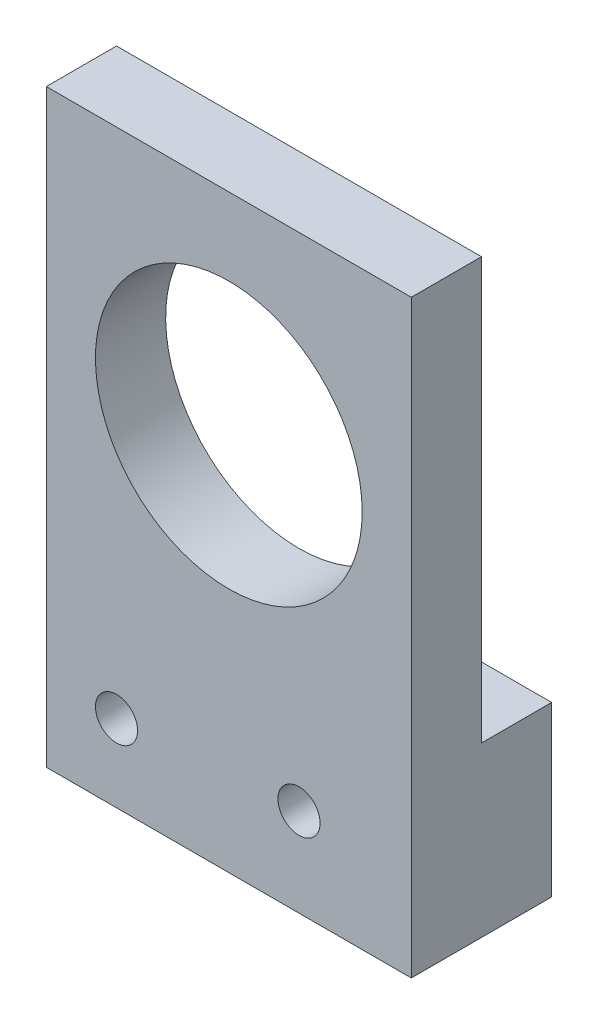
from build123d import *

# Parameters (mm, degrees)
CROQUIS1_W              = 26
CROQUIS1_H              = 42
CROQUIS1_R              = 9.5
CROQUIS1_R_2            = 1.5
SALIENTE_EXTRUIR1_DEPTH = 10
CROQUIS2_W              = 5
CROQUIS2_H              = 30
CORTAR_EXTRUIR1_DEPTH   = 40


with BuildPart() as part:
    # Croquis1 → Saliente-Extruir1 (new body)
    with BuildSketch(Plane.XY):
        with Locations((0, -6)):
            Rectangle(CROQUIS1_W, CROQUIS1_H)
        Circle(CROQUIS1_R, mode=Mode.SUBTRACT)
        with Locations((-8, -21.5)):
            Circle(CROQUIS1_R_2, mode=Mode.SUBTRACT)
        with Locations((5, -20.7)):
            Circle(CROQUIS1_R_2, mode=Mode.SUBTRACT)
    extrude(amount=SALIENTE_EXTRUIR1_DEPTH)

    # Croquis2 → Cortar-Extruir1 (cut)
    with BuildSketch(Plane.ZY.offset(13)):
        with Locations((2.5, 0)):
            Rectangle(CROQUIS2_W, CROQUIS2_H)
    extrude(amount=-CORTAR_EXTRUIR1_DEPTH, mode=Mode.SUBTRACT)


solid = part.part
